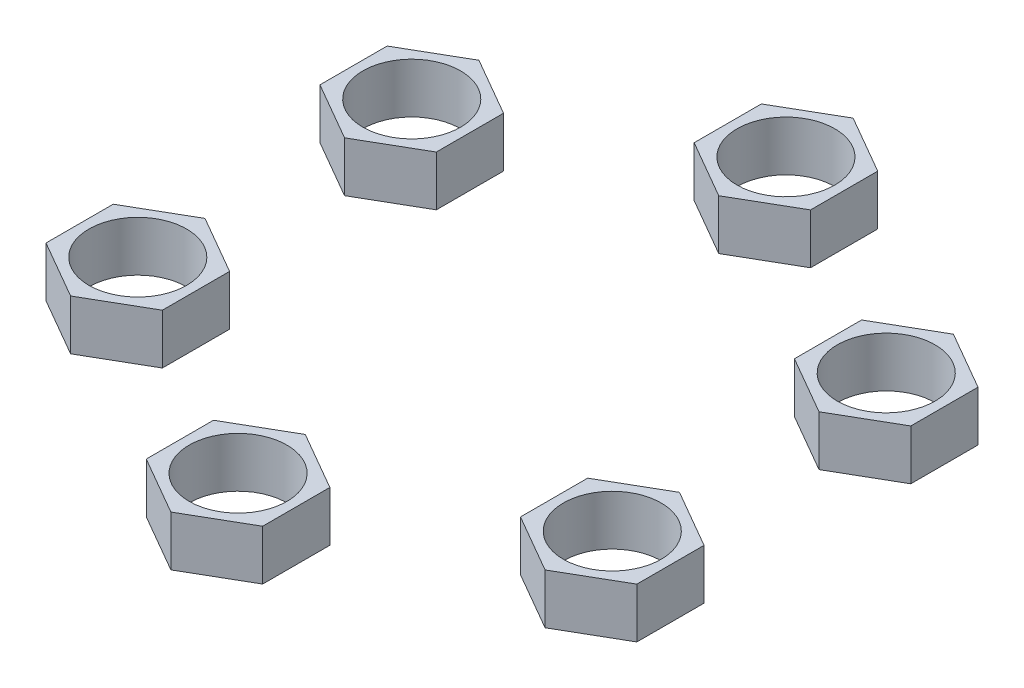
from build123d import *

# Parameters (mm, degrees)
SKETCH1_R             = 3.9
BOSS_EXTRUDE2_DEPTH   = 4
BOSS_EXTRUDE2_2_DEPTH = 4
BOSS_EXTRUDE2_3_DEPTH = 4
BOSS_EXTRUDE2_4_DEPTH = 4
BOSS_EXTRUDE2_5_DEPTH = 4
BOSS_EXTRUDE2_6_DEPTH = 4


with BuildPart() as part:
    # Sketch1 → Boss-Extrude2 (new body)
    with BuildSketch(Plane(origin=(0, 0, 0), x_dir=(1, 0, 0), z_dir=(0, 1, 0))):
        Polygon((14.294031961, 8.2526632), (18.939948877, 5.570341818), (23.585865794, 8.2526632), (23.585865794, 13.617305965), (18.939948877, 16.299627348), (14.294031961, 13.617305965), align=None)
        with Locations((18.939948877, 10.934984583)):
            Circle(SKETCH1_R, mode=Mode.SUBTRACT)
    extrude(amount=BOSS_EXTRUDE2_DEPTH)


with BuildPart() as body_2:
    # Sketch1 → Boss-Extrude2 2 (new body)
    with BuildSketch(Plane(origin=(0, 0, 0), x_dir=(1, 0, 0), z_dir=(0, 1, 0))):
        Polygon((0, 16.505326401), (4.645916917, 19.187647783), (4.645916917, 24.552290548), (0, 27.23461193), (-4.645916917, 24.552290548), (-4.645916917, 19.187647783), align=None)
        with Locations((0, 21.869969165)):
            Circle(SKETCH1_R, mode=Mode.SUBTRACT)
    extrude(amount=BOSS_EXTRUDE2_2_DEPTH)


with BuildPart() as body_3:
    # Sketch1 → Boss-Extrude2 3 (new body)
    with BuildSketch(Plane(origin=(0, 0, 0), x_dir=(1, 0, 0), z_dir=(0, 1, 0))):
        Polygon((14.294031961, -8.2526632), (14.294031961, -13.617305965), (18.939948877, -16.299627348), (23.585865794, -13.617305965), (23.585865794, -8.2526632), (18.939948877, -5.570341818), align=None)
        with Locations((18.939948877, -10.934984583)):
            Circle(SKETCH1_R, mode=Mode.SUBTRACT)
    extrude(amount=BOSS_EXTRUDE2_3_DEPTH)


with BuildPart() as body_4:
    # Sketch1 → Boss-Extrude2 4 (new body)
    with BuildSketch(Plane(origin=(0, 0, 0), x_dir=(1, 0, 0), z_dir=(0, 1, 0))):
        Polygon((0, -16.505326401), (-4.645916917, -19.187647783), (-4.645916917, -24.552290548), (0, -27.23461193), (4.645916917, -24.552290548), (4.645916917, -19.187647783), align=None)
        with Locations((0, -21.869969165)):
            Circle(SKETCH1_R, mode=Mode.SUBTRACT)
    extrude(amount=BOSS_EXTRUDE2_4_DEPTH)


with BuildPart() as body_5:
    # Sketch1 → Boss-Extrude2 5 (new body)
    with BuildSketch(Plane(origin=(0, 0, 0), x_dir=(1, 0, 0), z_dir=(0, 1, 0))):
        Polygon((-14.294031961, -8.2526632), (-18.939948877, -5.570341818), (-23.585865794, -8.2526632), (-23.585865794, -13.617305965), (-18.939948877, -16.299627348), (-14.294031961, -13.617305965), align=None)
        with Locations((-18.939948877, -10.934984583)):
            Circle(SKETCH1_R, mode=Mode.SUBTRACT)
    extrude(amount=BOSS_EXTRUDE2_5_DEPTH)


with BuildPart() as body_6:
    # Sketch1 → Boss-Extrude2 6 (new body)
    with BuildSketch(Plane(origin=(0, 0, 0), x_dir=(1, 0, 0), z_dir=(0, 1, 0))):
        Polygon((-14.294031961, 8.2526632), (-14.294031961, 13.617305965), (-18.939948877, 16.299627348), (-23.585865794, 13.617305965), (-23.585865794, 8.2526632), (-18.939948877, 5.570341818), align=None)
        with Locations((-18.939948877, 10.934984583)):
            Circle(SKETCH1_R, mode=Mode.SUBTRACT)
    extrude(amount=BOSS_EXTRUDE2_6_DEPTH)


solid = Compound([part.part, body_2.part, body_3.part, body_4.part, body_5.part, body_6.part])
